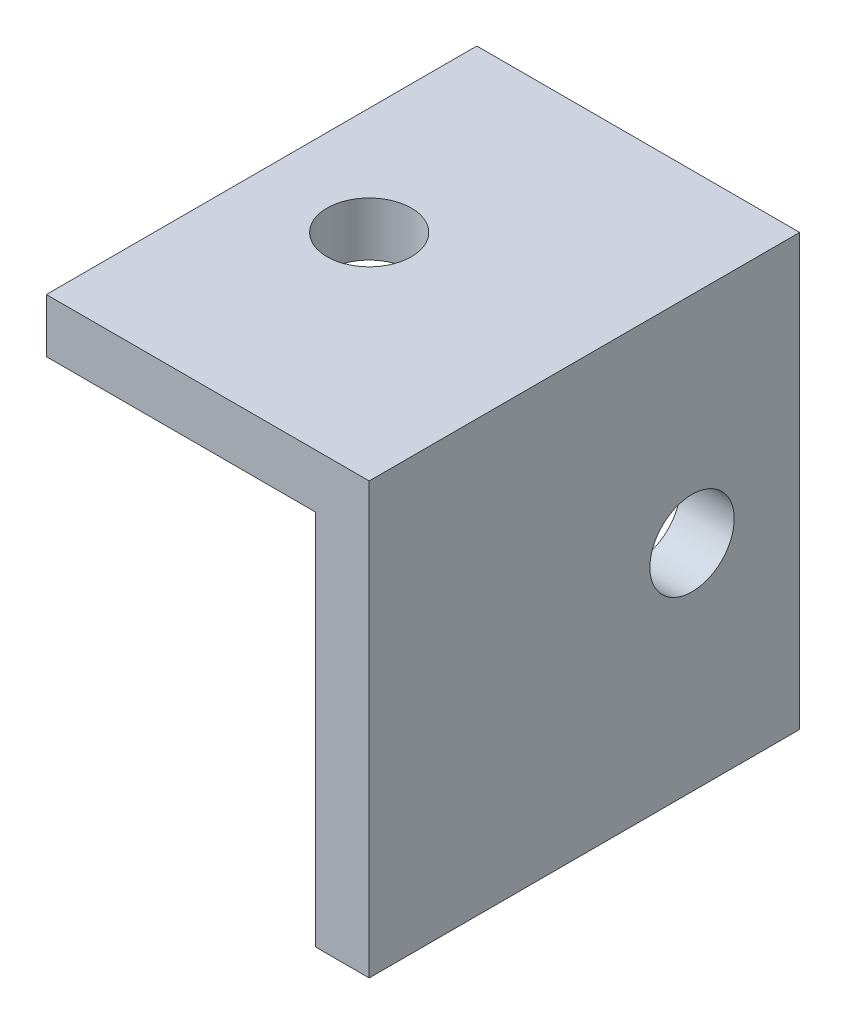
from build123d import *

# Parameters (mm, degrees)
EXTRUDE_THIN1_DEPTH            = 25.4
F_9_0_196_DIAMETER_HOLE1_D     = 4.9784
F_9_0_196_DIAMETER_HOLE1_DEPTH = 3.175
F_9_0_196_DIAMETER_HOLE3_D     = 4.9784
F_9_0_196_DIAMETER_HOLE3_DEPTH = 3.175
SKETCH11_W                     = 25.4
SKETCH11_H                     = 3.175
CUT_EXTRUDE1_DEPTH             = 6.35


with BuildPart() as part:
    # Sketch1 → Extrude-Thin1 (new body)
    with BuildSketch(Plane.XY):
        Polygon((-524.51, -25.4), (-524.51, 0), (-549.91, 0), (-549.91, -3.175), (-527.685, -3.175), (-527.685, -25.4), align=None)
    extrude(amount=-EXTRUDE_THIN1_DEPTH)

    # #9 (0.196) Diameter Hole1
    with Locations(Plane.ZY.offset(527.685)):
        with Locations((-19.05, -12.7)):
            Hole(F_9_0_196_DIAMETER_HOLE1_D / 2, depth=F_9_0_196_DIAMETER_HOLE1_DEPTH)

    # #9 (0.196) Diameter Hole3
    with Locations(Plane(origin=(0, -3.175, 0), x_dir=(-1, 0, 0), z_dir=(0, -1, 0))):
        with Locations((537.21, 12.7)):
            Hole(F_9_0_196_DIAMETER_HOLE3_D / 2, depth=F_9_0_196_DIAMETER_HOLE3_DEPTH)

    # Sketch11 → Cut-Extrude1 (cut)
    with BuildSketch(Plane.ZY.offset(549.91)):
        with Locations((-12.7, -1.5875)):
            Rectangle(SKETCH11_W, SKETCH11_H)
    extrude(amount=-CUT_EXTRUDE1_DEPTH, mode=Mode.SUBTRACT)


solid = part.part
